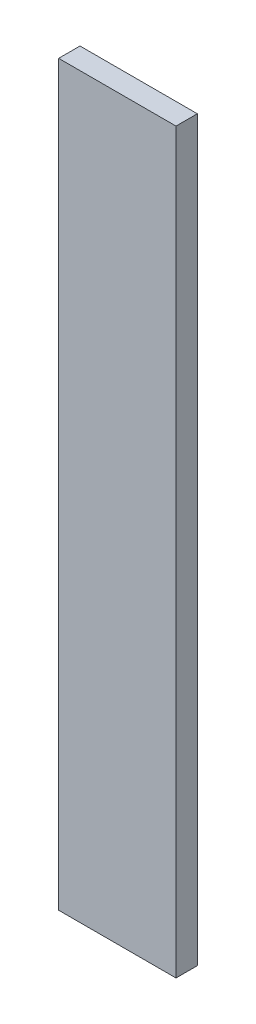
from build123d import *

# Parameters (mm, degrees)
BOSS_EXTRUDE1_DEPTH = 6
SKETCH2_W           = 66
SKETCH2_H           = 415
BOSS_EXTRUDE2_DEPTH = 6
SKETCH3_R           = 10
CUT_EXTRUDE1_DEPTH  = 6


with BuildPart() as part:
    # Sketch1 → Boss-Extrude1 (new body)
    with BuildSketch(Plane.XY):
        Polygon((23, 395), (23, 0), (43, 0), (43, 415), (-23, 415), (-23, 395), align=None)
    extrude(amount=-BOSS_EXTRUDE1_DEPTH)

    # Sketch2 → Boss-Extrude2 (add)
    with BuildSketch(Plane.XY):
        with Locations((10, 207.5)):
            Rectangle(SKETCH2_W, SKETCH2_H)
    extrude(amount=BOSS_EXTRUDE2_DEPTH)

    # Sketch3 → Cut-Extrude1 (cut)
    with BuildSketch(Plane(origin=(0, 0, -6), x_dir=(-1, 0, 0), z_dir=(0, 0, -1))):
        with Locations((-23, 395)):
            Circle(SKETCH3_R)
    extrude(amount=-CUT_EXTRUDE1_DEPTH, mode=Mode.SUBTRACT)


solid = part.part
